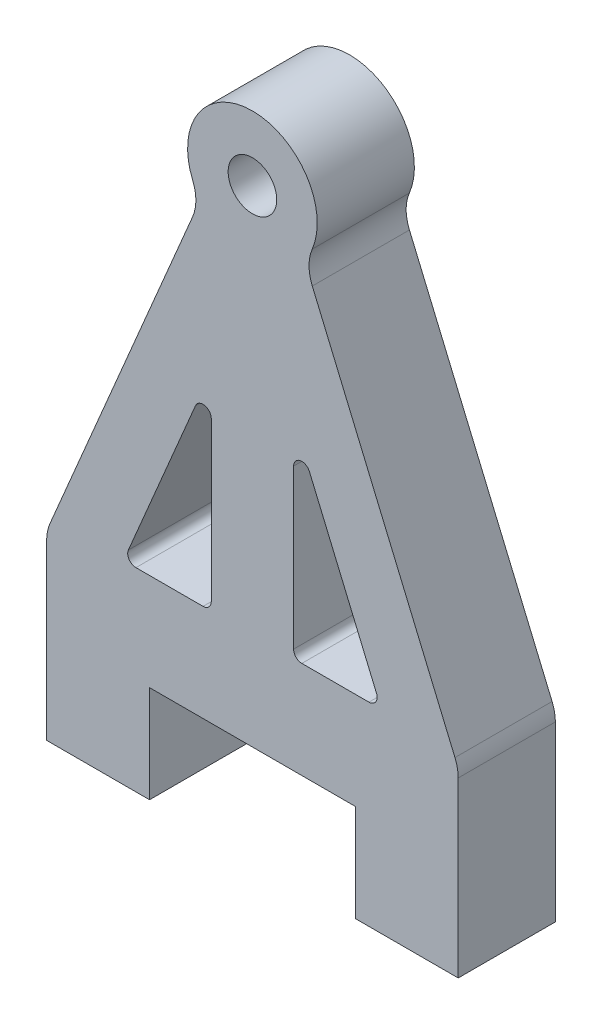
from build123d import *

# Parameters (mm, degrees)
SKETCH1_R           = 1.5
BOSS_EXTRUDE1_DEPTH = 5.9944


with BuildPart() as part:
    # Sketch1 → Boss-Extrude1 (new body)
    with BuildSketch(Plane.XY):
        with BuildLine():
            Line((-12.7, -25.303097847), (-12.7, -30))
            Line((-12.7, -30), (-12.7, -35.9944))
            Line((-12.7, -35.9944), (-6.35, -35.9944))
            Line((-6.35, -35.9944), (-6.35, -30))
            Line((-6.35, -30), (6.35, -30))
            Line((6.35, -30), (6.35, -35.9944))
            Line((6.35, -35.9944), (12.7, -35.9944))
            Line((12.7, -35.9944), (12.7, -30))
            Line((12.7, -30), (12.7, -25.303097847))
            ThreePointArc((12.7, -25.303097847), (12.649253454, -24.797907547), (12.499041543, -24.312903594))
            Line((12.499041543, -24.312903594), (3.694269669, -3.514229875))
            ThreePointArc((3.694269669, -3.514229875), (3.493316902, -2.529412233), (3.690098601, -1.543752674))
            ThreePointArc((3.690098601, -1.543752674), (0, 4), (-3.690098601, -1.543752674))
            ThreePointArc((-3.690098601, -1.543752674), (-3.493316902, -2.529412233), (-3.694269669, -3.514229875))
            Line((-3.694269669, -3.514229875), (-12.499041543, -24.312903594))
            ThreePointArc((-12.499041543, -24.312903594), (-12.649253454, -24.797907547), (-12.7, -25.303097847))
        make_face()
        with BuildLine():
            ThreePointArc((-2.54, -23.4976), (-2.688789755, -23.856810245), (-3.048, -24.0056))
            Line((-3.048, -24.0056), (-7.189093556, -24.0056))
            ThreePointArc((-7.189093556, -24.0056), (-7.612571853, -23.778188902), (-7.656901865, -23.299561149))
            Line((-7.656901865, -23.299561149), (-3.515808309, -13.517450387))
            ThreePointArc((-3.515808309, -13.517450387), (-2.94696194, -13.217638546), (-2.54, -13.715489237))
            Line((-2.54, -13.715489237), (-2.54, -23.4976))
        make_face(mode=Mode.SUBTRACT)
        with BuildLine():
            ThreePointArc((7.656901865, -23.299561149), (7.612571853, -23.778188902), (7.189093556, -24.0056))
            Line((7.189093556, -24.0056), (3.048, -24.0056))
            ThreePointArc((3.048, -24.0056), (2.688789755, -23.856810245), (2.54, -23.4976))
            Line((2.54, -23.4976), (2.54, -13.715489237))
            ThreePointArc((2.54, -13.715489237), (2.94696194, -13.217638546), (3.515808309, -13.517450387))
            Line((3.515808309, -13.517450387), (7.656901865, -23.299561149))
        make_face(mode=Mode.SUBTRACT)
        Circle(SKETCH1_R, mode=Mode.SUBTRACT)
    extrude(amount=BOSS_EXTRUDE1_DEPTH)


solid = part.part
